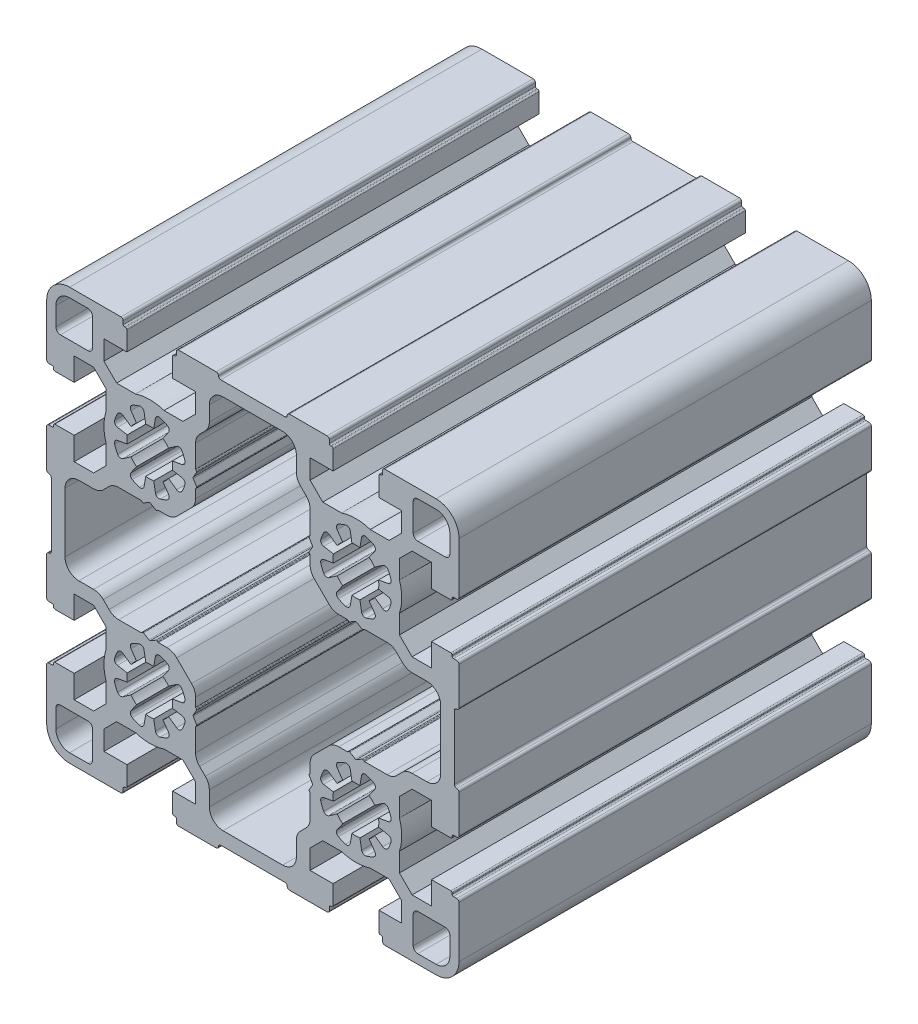
from build123d import *

# Parameters (mm, degrees)
BASE_EXTRUDE_DEPTH = 90


with BuildPart() as part:
    # Sketch1 → Base-Extrude (new body)
    with BuildSketch(Plane.XY):
        with BuildLine():
            Line((12.500065, -34.76272304), (15.262800475, -31.999987565))
            Line((15.262800475, -31.999987565), (19.377553245, -31.999987565))
            ThreePointArc((19.377553245, -31.999987565), (22.500045, -32.499985925), (25.622536755, -31.999987565))
            Line((25.622536755, -31.999987565), (29.737289525, -31.999987565))
            Line((29.737289525, -31.999987565), (32.500025, -34.76272304))
            Line((32.500025, -34.76272304), (32.500025, -39.000012))
            Line((32.500025, -39.000012), (27.500215, -39.000012))
            Line((27.500215, -39.000012), (27.500215, -43.2000036))
            ThreePointArc((27.500215, -43.2000036), (27.588084224, -43.412135897), (27.8002174, -43.500003))
            Line((27.8002174, -43.500003), (28.000214, -43.500003))
            ThreePointArc((28.000214, -43.500003), (28.212343176, -43.58787176), (28.3002084, -43.8000024))
            Line((28.3002084, -43.8000024), (28.3002084, -44.500001))
            ThreePointArc((28.3002084, -44.500001), (28.446654607, -44.853553793), (28.8002074, -45))
            Line((28.8002074, -45), (40.000013735, -45))
            ThreePointArc((40.000013735, -45), (43.535537929, -43.535537929), (45, -40.000013735))
            Line((45, -40.000013735), (45, -28.7999414))
            ThreePointArc((45, -28.7999414), (44.853553793, -28.446388607), (44.500001, -28.2999424))
            Line((44.500001, -28.2999424), (43.8000054, -28.2999424))
            ThreePointArc((43.8000054, -28.2999424), (43.587872431, -28.212075797), (43.500003, -27.999944))
            Line((43.500003, -27.999944), (43.500003, -27.7999434))
            ThreePointArc((43.500003, -27.7999434), (43.412133569, -27.587811603), (43.2000006, -27.499945))
            Line((43.2000006, -27.499945), (39.000192, -27.499945))
            Line((39.000192, -27.499945), (39.000192, -32.499935))
            Line((39.000192, -32.499935), (34.762941475, -32.499935))
            Line((34.762941475, -32.499935), (32.000206, -29.737198525))
            Line((32.000206, -29.737198525), (32.000206, -25.622447755))
            ThreePointArc((32.000206, -25.622447755), (32.50020452, -22.499955), (32.000206, -19.377462245))
            Line((32.000206, -19.377462245), (32.000206, -15.262710475))
            Line((32.000206, -15.262710475), (34.762941475, -12.499975))
            Line((34.762941475, -12.499975), (39.000012, -12.499975))
            Line((39.000012, -12.499975), (39.000012, -17.499965))
            Line((39.000012, -17.499965), (43.2000006, -17.499965))
            ThreePointArc((43.2000006, -17.499965), (43.412133569, -17.412098397), (43.500003, -17.1999666))
            Line((43.500003, -17.1999666), (43.500003, -16.999966))
            ThreePointArc((43.500003, -16.999966), (43.587872431, -16.787834203), (43.8000054, -16.6999676))
            Line((43.8000054, -16.6999676), (44.500001, -16.6999676))
            ThreePointArc((44.500001, -16.6999676), (44.853553793, -16.553521393), (45, -16.1999686))
            Line((45, -16.1999686), (45, -7.999984))
            ThreePointArc((45, -7.999984), (44.853553793, -7.646431207), (44.500001, -7.499985))
            ThreePointArc((44.500001, -7.499985), (44.146448207, -7.353538793), (44.000002, -6.999986))
            Line((44.000002, -6.999986), (44.000002, 6.999986))
            ThreePointArc((44.000002, 6.999986), (44.146448207, 7.353538793), (44.500001, 7.499985))
            ThreePointArc((44.500001, 7.499985), (44.853553793, 7.646431207), (45, 7.999984))
            Line((45, 7.999984), (45, 16.1999686))
            ThreePointArc((45, 16.1999686), (44.853553793, 16.553521393), (44.500001, 16.6999676))
            Line((44.500001, 16.6999676), (43.8000054, 16.6999676))
            ThreePointArc((43.8000054, 16.6999676), (43.587872431, 16.787834203), (43.500003, 16.999966))
            Line((43.500003, 16.999966), (43.500003, 17.1999666))
            ThreePointArc((43.500003, 17.1999666), (43.412133569, 17.412098397), (43.2000006, 17.499965))
            Line((43.2000006, 17.499965), (39.000192, 17.499965))
            Line((39.000192, 17.499965), (39.000192, 12.50002))
            Line((39.000192, 12.50002), (34.762941474, 12.50002))
            Line((34.762941474, 12.50002), (32.000206, 15.262755474))
            Line((32.000206, 15.262755474), (32.000206, 19.377508245))
            ThreePointArc((32.000206, 19.377508245), (32.50020436, 22.5), (32.000206, 25.622491755))
            Line((32.000206, 25.622491755), (32.000206, 29.737244525))
            Line((32.000206, 29.737244525), (34.762941474, 32.49998))
            Line((34.762941474, 32.49998), (39.000012, 32.49998))
            Line((39.000012, 32.49998), (39.000012, 27.500125))
            Line((39.000012, 27.500125), (43.2000006, 27.500125))
            ThreePointArc((43.2000006, 27.500125), (43.412134397, 27.587993603), (43.500003, 27.8001274))
            Line((43.500003, 27.8001274), (43.500003, 28.000124))
            ThreePointArc((43.500003, 28.000124), (43.58787326, 28.212253797), (43.8000054, 28.3001184))
            Line((43.8000054, 28.3001184), (44.500001, 28.3001184))
            ThreePointArc((44.500001, 28.3001184), (44.853553793, 28.446564607), (45, 28.8001174))
            Line((45, 28.8001174), (45, 40.000013735))
            ThreePointArc((45, 40.000013735), (43.535537929, 43.535537929), (40.000013735, 45))
            Line((40.000013735, 45), (28.8000354, 45))
            ThreePointArc((28.8000354, 45), (28.446482607, 44.853553793), (28.3000364, 44.500001))
            Line((28.3000364, 44.500001), (28.3000364, 43.8000054))
            ThreePointArc((28.3000364, 43.8000054), (28.212167797, 43.587871603), (28.000034, 43.500003))
            Line((28.000034, 43.500003), (27.8000374, 43.500003))
            ThreePointArc((27.8000374, 43.500003), (27.587903603, 43.412134397), (27.500035, 43.2000006))
            Line((27.500035, 43.2000006), (27.500035, 39.000012))
            Line((27.500035, 39.000012), (32.499865, 39.000012))
            Line((32.499865, 39.000012), (32.499865, 34.762761475))
            Line((32.499865, 34.762761475), (29.737129525, 32.000026))
            Line((29.737129525, 32.000026), (25.622376755, 32.000026))
            ThreePointArc((25.622376755, 32.000026), (22.499885, 32.50002436), (19.377393245, 32.000026))
            Line((19.377393245, 32.000026), (15.262640475, 32.000026))
            Line((15.262640475, 32.000026), (12.499905, 34.762761475))
            Line((12.499905, 34.762761475), (12.499905, 39.000012))
            Line((12.499905, 39.000012), (17.499895, 39.000012))
            Line((17.499895, 39.000012), (17.499895, 43.2000006))
            ThreePointArc((17.499895, 43.2000006), (17.412028397, 43.412133569), (17.1998966, 43.500003))
            Line((17.1998966, 43.500003), (16.999896, 43.500003))
            ThreePointArc((16.999896, 43.500003), (16.787764203, 43.587872431), (16.6998976, 43.8000054))
            Line((16.6998976, 43.8000054), (16.6998976, 44.500001))
            ThreePointArc((16.6998976, 44.500001), (16.553451393, 44.853553793), (16.1998986, 45))
            Line((16.1998986, 45), (7.999914, 45))
            ThreePointArc((7.999914, 45), (7.646361207, 44.853553793), (7.499915, 44.500001))
            ThreePointArc((7.499915, 44.500001), (7.353468793, 44.146448207), (6.999916, 44.000002))
            Line((6.999916, 44.000002), (-7.000056, 44.000002))
            ThreePointArc((-7.000056, 44.000002), (-7.353608793, 44.146448207), (-7.500055, 44.500001))
            ThreePointArc((-7.500055, 44.500001), (-7.646501207, 44.853553793), (-8.000054, 45))
            Line((-8.000054, 45), (-16.2000386, 45))
            ThreePointArc((-16.2000386, 45), (-16.553591393, 44.853553793), (-16.7000376, 44.500001))
            Line((-16.7000376, 44.500001), (-16.7000376, 43.8000054))
            ThreePointArc((-16.7000376, 43.8000054), (-16.787904203, 43.587872431), (-17.000036, 43.500003))
            Line((-17.000036, 43.500003), (-17.2000366, 43.500003))
            ThreePointArc((-17.2000366, 43.500003), (-17.412168397, 43.412133569), (-17.500035, 43.2000006))
            Line((-17.500035, 43.2000006), (-17.500035, 39.000012))
            Line((-17.500035, 39.000012), (-12.500065, 39.000012))
            Line((-12.500065, 39.000012), (-12.500065, 34.762761475))
            Line((-12.500065, 34.762761475), (-15.262800475, 32.000026))
            Line((-15.262800475, 32.000026), (-19.377552245, 32.000026))
            ThreePointArc((-19.377552245, 32.000026), (-22.500045, 32.50002452), (-25.622537755, 32.000026))
            Line((-25.622537755, 32.000026), (-29.737288525, 32.000026))
            Line((-29.737288525, 32.000026), (-32.500025, 34.762761475))
            Line((-32.500025, 34.762761475), (-32.500025, 39.000012))
            Line((-32.500025, 39.000012), (-27.500035, 39.000012))
            Line((-27.500035, 39.000012), (-27.500035, 43.2000006))
            ThreePointArc((-27.500035, 43.2000006), (-27.587901603, 43.412133569), (-27.8000334, 43.500003))
            Line((-27.8000334, 43.500003), (-28.000034, 43.500003))
            ThreePointArc((-28.000034, 43.500003), (-28.212165797, 43.587872431), (-28.3000324, 43.8000054))
            Line((-28.3000324, 43.8000054), (-28.3000324, 44.500001))
            ThreePointArc((-28.3000324, 44.500001), (-28.446478607, 44.853553793), (-28.8000314, 45))
            Line((-28.8000314, 45), (-40.000013735, 45))
            ThreePointArc((-40.000013735, 45), (-43.535537929, 43.535537929), (-45, 40.000013735))
            Line((-45, 40.000013735), (-45, 28.7999454))
            ThreePointArc((-45, 28.7999454), (-44.853553793, 28.446392607), (-44.500001, 28.2999464))
            Line((-44.500001, 28.2999464), (-43.8000024, 28.2999464))
            ThreePointArc((-43.8000024, 28.2999464), (-43.587870103, 28.212077176), (-43.500003, 27.999944))
            Line((-43.500003, 27.999944), (-43.500003, 27.7999474))
            ThreePointArc((-43.500003, 27.7999474), (-43.412135897, 27.587814224), (-43.2000036, 27.499945))
            Line((-43.2000036, 27.499945), (-39.000012, 27.499945))
            Line((-39.000012, 27.499945), (-39.000012, 32.499935))
            Line((-39.000012, 32.499935), (-34.762761475, 32.499935))
            Line((-34.762761475, 32.499935), (-32.000026, 29.737199525))
            Line((-32.000026, 29.737199525), (-32.000026, 25.622446755))
            ThreePointArc((-32.000026, 25.622446755), (-32.50002436, 22.499955), (-32.000026, 19.377463245))
            Line((-32.000026, 19.377463245), (-32.000026, 15.262710475))
            Line((-32.000026, 15.262710475), (-34.762761475, 12.499975))
            Line((-34.762761475, 12.499975), (-39.000012, 12.499975))
            Line((-39.000012, 12.499975), (-39.000012, 17.499965))
            Line((-39.000012, 17.499965), (-43.2000036, 17.499965))
            ThreePointArc((-43.2000036, 17.499965), (-43.412135069, 17.412097776), (-43.500003, 17.1999666))
            Line((-43.500003, 17.1999666), (-43.500003, 16.999966))
            ThreePointArc((-43.500003, 16.999966), (-43.587870931, 16.787834824), (-43.8000024, 16.6999676))
            Line((-43.8000024, 16.6999676), (-44.500001, 16.6999676))
            ThreePointArc((-44.500001, 16.6999676), (-44.853553793, 16.553521393), (-45, 16.1999686))
            Line((-45, 16.1999686), (-45, 7.999984))
            ThreePointArc((-45, 7.999984), (-44.853553793, 7.646431207), (-44.500001, 7.499985))
            ThreePointArc((-44.500001, 7.499985), (-44.146448207, 7.353538793), (-44.000002, 6.999986))
            Line((-44.000002, 6.999986), (-44.000002, -6.999986))
            ThreePointArc((-44.000002, -6.999986), (-44.146448207, -7.353538793), (-44.500001, -7.499985))
            ThreePointArc((-44.500001, -7.499985), (-44.853553793, -7.646431207), (-45, -7.999984))
            Line((-45, -7.999984), (-45, -16.1999686))
            ThreePointArc((-45, -16.1999686), (-44.853553793, -16.553521393), (-44.500001, -16.6999676))
            Line((-44.500001, -16.6999676), (-43.8000024, -16.6999676))
            ThreePointArc((-43.8000024, -16.6999676), (-43.587870931, -16.787834824), (-43.500003, -16.999966))
            Line((-43.500003, -16.999966), (-43.500003, -17.1999666))
            ThreePointArc((-43.500003, -17.1999666), (-43.412135069, -17.412097776), (-43.2000036, -17.499965))
            Line((-43.2000036, -17.499965), (-39.000012, -17.499965))
            Line((-39.000012, -17.499965), (-39.000012, -12.499975))
            Line((-39.000012, -12.499975), (-34.762761475, -12.499975))
            Line((-34.762761475, -12.499975), (-32.000026, -15.262710475))
            Line((-32.000026, -15.262710475), (-32.000026, -19.377462245))
            ThreePointArc((-32.000026, -19.377462245), (-32.50002452, -22.499955), (-32.000026, -25.622447755))
            Line((-32.000026, -25.622447755), (-32.000026, -29.737198525))
            Line((-32.000026, -29.737198525), (-34.762761475, -32.499935))
            Line((-34.762761475, -32.499935), (-39.000012, -32.499935))
            Line((-39.000012, -32.499935), (-39.000012, -27.499945))
            Line((-39.000012, -27.499945), (-43.2000036, -27.499945))
            ThreePointArc((-43.2000036, -27.499945), (-43.412135069, -27.587812224), (-43.500003, -27.7999434))
            Line((-43.500003, -27.7999434), (-43.500003, -27.999944))
            ThreePointArc((-43.500003, -27.999944), (-43.587870931, -28.212075176), (-43.8000024, -28.2999424))
            Line((-43.8000024, -28.2999424), (-44.500001, -28.2999424))
            ThreePointArc((-44.500001, -28.2999424), (-44.853553793, -28.446388607), (-45, -28.7999414))
            Line((-45, -28.7999414), (-45, -40.000013735))
            ThreePointArc((-45, -40.000013735), (-43.535537929, -43.535537929), (-40.000013735, -45))
            Line((-40.000013735, -45), (-28.8000314, -45))
            ThreePointArc((-28.8000314, -45), (-28.446478607, -44.853553793), (-28.3000324, -44.500001))
            Line((-28.3000324, -44.500001), (-28.3000324, -43.8000024))
            ThreePointArc((-28.3000324, -43.8000024), (-28.212165176, -43.587870931), (-28.000034, -43.500003))
            Line((-28.000034, -43.500003), (-27.8000334, -43.500003))
            ThreePointArc((-27.8000334, -43.500003), (-27.587902224, -43.412135069), (-27.500035, -43.2000036))
            Line((-27.500035, -43.2000036), (-27.500035, -39.000012))
            Line((-27.500035, -39.000012), (-32.500025, -39.000012))
            Line((-32.500025, -39.000012), (-32.500025, -34.762761475))
            Line((-32.500025, -34.762761475), (-29.737288525, -32.000026))
            Line((-29.737288525, -32.000026), (-25.622537755, -32.000026))
            ThreePointArc((-25.622537755, -32.000026), (-22.500045, -32.50002452), (-19.377552245, -32.000026))
            Line((-19.377552245, -32.000026), (-15.262800475, -32.000026))
            Line((-15.262800475, -32.000026), (-12.500065, -34.762761475))
            Line((-12.500065, -34.762761475), (-12.500065, -39.000012))
            Line((-12.500065, -39.000012), (-17.500055, -39.000012))
            Line((-17.500055, -39.000012), (-17.500055, -43.2000036))
            ThreePointArc((-17.500055, -43.2000036), (-17.412187776, -43.412135069), (-17.2000566, -43.500003))
            Line((-17.2000566, -43.500003), (-17.000056, -43.500003))
            ThreePointArc((-17.000056, -43.500003), (-16.787924824, -43.587870931), (-16.7000576, -43.8000024))
            Line((-16.7000576, -43.8000024), (-16.7000576, -44.500001))
            ThreePointArc((-16.7000576, -44.500001), (-16.553611393, -44.853553793), (-16.2000586, -45))
            Line((-16.2000586, -45), (-8.000074, -45))
            ThreePointArc((-8.000074, -45), (-7.646521207, -44.853553793), (-7.500075, -44.500001))
            ThreePointArc((-7.500075, -44.500001), (-7.353628793, -44.146448207), (-7.000076, -44.000002))
            Line((-7.000076, -44.000002), (6.999896, -44.000002))
            ThreePointArc((6.999896, -44.000002), (7.353448793, -44.146448207), (7.499895, -44.500001))
            ThreePointArc((7.499895, -44.500001), (7.646341207, -44.853553793), (7.999894, -45))
            Line((7.999894, -45), (16.1998786, -45))
            ThreePointArc((16.1998786, -45), (16.553431393, -44.853553793), (16.6998776, -44.500001))
            Line((16.6998776, -44.500001), (16.6998776, -43.8000024))
            ThreePointArc((16.6998776, -43.8000024), (16.787744824, -43.587870931), (16.999876, -43.500003))
            Line((16.999876, -43.500003), (17.1998766, -43.500003))
            ThreePointArc((17.1998766, -43.500003), (17.412007776, -43.412135069), (17.499875, -43.2000036))
            Line((17.499875, -43.2000036), (17.499875, -38.999973565))
            Line((17.499875, -38.999973565), (12.500065, -38.999973565))
            Line((12.500065, -38.999973565), (12.500065, -34.76272304))
        make_face()
        with BuildLine():
            Line((12.294798432, -21.132865734), (12.989033032, -22.335315335))
            ThreePointArc((12.989033032, -22.335315335), (13.029225168, -22.485314535), (12.989033032, -22.635313735))
            Line((12.989033032, -22.635313735), (12.277891455, -23.867044272))
            ThreePointArc((12.277891455, -23.867044272), (12.252807503, -23.993150123), (12.309675391, -24.108466789))
            Line((12.309675391, -24.108466789), (12.441397128, -24.240185526))
            ThreePointArc((12.441397128, -24.240185526), (12.484751208, -24.305069962), (12.499975011, -24.381606243))
            Line((12.499975011, -24.381606243), (12.499975011, -29.277400451))
            ThreePointArc((12.499975011, -29.277400451), (12.271612969, -30.425448253), (11.621295768, -31.398716209))
            Line((11.621295768, -31.398716209), (10.378660253, -32.641354723))
            ThreePointArc((10.378660253, -32.641354723), (9.728343052, -33.614622679), (9.499981011, -34.762670481))
            Line((9.499981011, -34.762670481), (9.499981011, -37.999924006))
            ThreePointArc((9.499981011, -37.999924006), (8.621303768, -40.121240763), (6.499987011, -40.999918006))
            Line((6.499987011, -40.999918006), (-6.499986989, -40.999918006))
            ThreePointArc((-6.499986989, -40.999918006), (-8.621303747, -40.121240763), (-9.499980989, -37.999924006))
            Line((-9.499980989, -37.999924006), (-9.499980989, -34.762670481))
            ThreePointArc((-9.499980989, -34.762670481), (-9.728343031, -33.614622679), (-10.378660232, -32.641354723))
            Line((-10.378660232, -32.641354723), (-11.621295747, -31.398716209))
            ThreePointArc((-11.621295747, -31.398716209), (-12.271612948, -30.425448253), (-12.499974989, -29.277400451))
            Line((-12.499974989, -29.277400451), (-12.499974989, -24.381606243))
            ThreePointArc((-12.499974989, -24.381606243), (-12.484751187, -24.305069962), (-12.441397107, -24.240185526))
            Line((-12.441397107, -24.240185526), (-12.30967537, -24.108466789))
            ThreePointArc((-12.30967537, -24.108466789), (-12.252807482, -23.993150123), (-12.277891434, -23.867044272))
            Line((-12.277891434, -23.867044272), (-12.989033011, -22.635313735))
            ThreePointArc((-12.989033011, -22.635313735), (-13.029225147, -22.485314535), (-12.989033011, -22.335315335))
            Line((-12.989033011, -22.335315335), (-12.29479841, -21.132865734))
            ThreePointArc((-12.29479841, -21.132865734), (-12.269714459, -21.006759883), (-12.326582347, -20.891443217))
            Line((-12.326582347, -20.891443217), (-12.441397117, -20.776630447))
            ThreePointArc((-12.441397117, -20.776630447), (-12.484751098, -20.71174651), (-12.499975, -20.635210729))
            Line((-12.499975, -20.635210729), (-12.499975, -18.742602515))
            ThreePointArc((-12.499975, -18.742602515), (-12.728335682, -17.594552774), (-13.378654243, -16.621283757))
            Line((-13.378654243, -16.621283757), (-16.621289757, -13.378652243))
            ThreePointArc((-16.621289757, -13.378652243), (-17.594557912, -12.728336041), (-18.742605515, -12.499975))
            Line((-18.742605515, -12.499975), (-20.63520673, -12.499975))
            ThreePointArc((-20.63520673, -12.499975), (-20.71174301, -12.484751197), (-20.776627447, -12.441397117))
            Line((-20.776627447, -12.441397117), (-20.891441217, -12.326582347))
            ThreePointArc((-20.891441217, -12.326582347), (-21.006756883, -12.269714798), (-21.132861734, -12.29479841))
            Line((-21.132861734, -12.29479841), (-22.335315329, -12.989033022))
            ThreePointArc((-22.335315329, -12.989033022), (-22.485314529, -13.029225158), (-22.635313729, -12.989033022))
            Line((-22.635313729, -12.989033022), (-23.867048266, -12.277891444))
            ThreePointArc((-23.867048266, -12.277891444), (-23.993154148, -12.252807251), (-24.108470783, -12.309675381))
            Line((-24.108470783, -12.309675381), (-24.24018552, -12.441397117))
            ThreePointArc((-24.24018552, -12.441397117), (-24.305070898, -12.484751538), (-24.381608237, -12.499975))
            Line((-24.381608237, -12.499975), (-29.277400445, -12.499975))
            ThreePointArc((-29.277400445, -12.499975), (-30.425446849, -12.27161476), (-31.398714202, -11.621299757))
            Line((-31.398714202, -11.621299757), (-32.641359717, -10.378656243))
            ThreePointArc((-32.641359717, -10.378656243), (-33.614627071, -9.72834124), (-34.762673475, -9.499981))
            Line((-34.762673475, -9.499981), (-37.999924, -9.499981))
            ThreePointArc((-37.999924, -9.499981), (-40.121240757, -8.621303757), (-40.999918, -6.499987))
            Line((-40.999918, -6.499987), (-40.999918, 6.499987))
            ThreePointArc((-40.999918, 6.499987), (-40.121240757, 8.621303757), (-37.999924, 9.499981))
            Line((-37.999924, 9.499981), (-34.762673475, 9.499981))
            ThreePointArc((-34.762673475, 9.499981), (-33.614627071, 9.72834124), (-32.641359717, 10.378656243))
            Line((-32.641359717, 10.378656243), (-31.398714202, 11.621299757))
            ThreePointArc((-31.398714202, 11.621299757), (-30.425446849, 12.27161476), (-29.277400445, 12.499975))
            Line((-29.277400445, 12.499975), (-24.381608237, 12.499975))
            ThreePointArc((-24.381608237, 12.499975), (-24.305070898, 12.484751538), (-24.24018552, 12.441397117))
            Line((-24.24018552, 12.441397117), (-24.108470783, 12.309675381))
            ThreePointArc((-24.108470783, 12.309675381), (-23.993154148, 12.252807251), (-23.867048266, 12.277891444))
            Line((-23.867048266, 12.277891444), (-22.635313729, 12.989033022))
            ThreePointArc((-22.635313729, 12.989033022), (-22.485314529, 13.029225158), (-22.335315329, 12.989033022))
            Line((-22.335315329, 12.989033022), (-21.132861734, 12.29479841))
            ThreePointArc((-21.132861734, 12.29479841), (-21.006756883, 12.269714798), (-20.891441217, 12.326582347))
            Line((-20.891441217, 12.326582347), (-20.776627447, 12.441397117))
            ThreePointArc((-20.776627447, 12.441397117), (-20.71174301, 12.484751197), (-20.63520673, 12.499975))
            Line((-20.63520673, 12.499975), (-18.742605515, 12.499975))
            ThreePointArc((-18.742605515, 12.499975), (-17.594558111, 12.728335041), (-16.621289757, 13.378650243))
            Line((-16.621289757, 13.378650243), (-13.378654243, 16.621285757))
            ThreePointArc((-13.378654243, 16.621285757), (-12.72833608, 17.594552774), (-12.499975, 18.742600515))
            Line((-12.499975, 18.742600515), (-12.499975, 20.635212729))
            ThreePointArc((-12.499975, 20.635212729), (-12.484750899, 20.71174751), (-12.441397117, 20.776630447))
            Line((-12.441397117, 20.776630447), (-12.326582347, 20.891445217))
            ThreePointArc((-12.326582347, 20.891445217), (-12.269715477, 21.006758883), (-12.29479841, 21.132861734))
            Line((-12.29479841, 21.132861734), (-12.989033022, 22.335313329))
            ThreePointArc((-12.989033022, 22.335313329), (-13.029225693, 22.485314529), (-12.989033022, 22.635315729))
            Line((-12.989033022, 22.635315729), (-12.277891444, 23.867048266))
            ThreePointArc((-12.277891444, 23.867048266), (-12.252808511, 23.993151117), (-12.309675381, 24.108464783))
            Line((-12.309675381, 24.108464783), (-12.441397117, 24.24018552))
            ThreePointArc((-12.441397117, 24.24018552), (-12.484750999, 24.305068956), (-12.499975, 24.381604237))
            Line((-12.499975, 24.381604237), (-12.499975, 29.277399445))
            ThreePointArc((-12.499975, 29.277399445), (-12.271613257, 30.425448747), (-11.621295757, 31.398718202))
            Line((-11.621295757, 31.398718202), (-10.378660243, 32.641352717))
            ThreePointArc((-10.378660243, 32.641352717), (-9.728342743, 33.614622173), (-9.499981, 34.762671475))
            Line((-9.499981, 34.762671475), (-9.499981, 37.999924))
            ThreePointArc((-9.499981, 37.999924), (-8.62130376, 40.121240761), (-6.499987, 40.999918006))
            Line((-6.499987, 40.999918006), (6.499987, 40.999918006))
            ThreePointArc((6.499987, 40.999918006), (8.621303757, 40.121240763), (9.499981, 37.999924006))
            Line((9.499981, 37.999924006), (9.499981, 34.762671481))
            ThreePointArc((9.499981, 34.762671481), (9.728342743, 33.614622179), (10.378660243, 32.641352723))
            Line((10.378660243, 32.641352723), (11.621295757, 31.398718209))
            ThreePointArc((11.621295757, 31.398718209), (12.271613257, 30.425448753), (12.499975, 29.277399451))
            Line((12.499975, 29.277399451), (12.499975, 24.381604243))
            ThreePointArc((12.499975, 24.381604243), (12.484750999, 24.305068962), (12.441397117, 24.240185526))
            Line((12.441397117, 24.240185526), (12.309675381, 24.108464789))
            ThreePointArc((12.309675381, 24.108464789), (12.252808511, 23.993151123), (12.277891444, 23.867048272))
            Line((12.277891444, 23.867048272), (12.989033022, 22.635315735))
            ThreePointArc((12.989033022, 22.635315735), (13.029225693, 22.485314535), (12.989033022, 22.335313335))
            Line((12.989033022, 22.335313335), (12.29479841, 21.13286174))
            ThreePointArc((12.29479841, 21.13286174), (12.269715477, 21.00675889), (12.326582347, 20.891445223))
            Line((12.326582347, 20.891445223), (12.441397117, 20.776630453))
            ThreePointArc((12.441397117, 20.776630453), (12.484750899, 20.711747516), (12.499975, 20.635212736))
            Line((12.499975, 20.635212736), (12.499975, 18.742600521))
            ThreePointArc((12.499975, 18.742600521), (12.72833608, 17.59455278), (13.378654243, 16.621285763))
            Line((13.378654243, 16.621285763), (16.621289757, 13.378650249))
            ThreePointArc((16.621289757, 13.378650249), (17.594557111, 12.728335246), (18.742603515, 12.499975006))
            Line((18.742603515, 12.499975006), (20.63520473, 12.499975006))
            ThreePointArc((20.63520473, 12.499975006), (20.71174351, 12.484751701), (20.776630447, 12.441397123))
            Line((20.776630447, 12.441397123), (20.891437217, 12.326582353))
            ThreePointArc((20.891437217, 12.326582353), (21.006754883, 12.269714126), (21.132861734, 12.294798416))
            Line((21.132861734, 12.294798416), (22.335313329, 12.989033028))
            ThreePointArc((22.335313329, 12.989033028), (22.485314529, 13.0292257), (22.635315729, 12.989033028))
            Line((22.635315729, 12.989033028), (23.867048266, 12.27789145))
            ThreePointArc((23.867048266, 12.27789145), (23.993155148, 12.252806918), (24.108472783, 12.309675387))
            Line((24.108472783, 12.309675387), (24.24018552, 12.441397123))
            ThreePointArc((24.24018552, 12.441397123), (24.305072398, 12.484751842), (24.381611237, 12.499975006))
            Line((24.381611237, 12.499975006), (29.277399445, 12.499975006))
            ThreePointArc((29.277399445, 12.499975006), (30.425444349, 12.271614467), (31.398710202, 11.621299763))
            Line((31.398710202, 11.621299763), (32.641360717, 10.378656249))
            ThreePointArc((32.641360717, 10.378656249), (33.614626571, 9.728341545), (34.762671475, 9.499981006))
            Line((34.762671475, 9.499981006), (37.999924, 9.499981006))
            ThreePointArc((37.999924, 9.499981006), (40.12124076, 8.621303761), (40.999918, 6.499987))
            Line((40.999918, 6.499987), (40.999918, -6.499987))
            ThreePointArc((40.999918, -6.499987), (40.121240765, -8.62130375), (37.999924021, -9.499981))
            Line((37.999924021, -9.499981), (34.762671496, -9.499981))
            ThreePointArc((34.762671496, -9.499981), (33.614626592, -9.728341539), (32.641360738, -10.378656243))
            Line((32.641360738, -10.378656243), (31.398710224, -11.621299757))
            ThreePointArc((31.398710224, -11.621299757), (30.42544437, -12.271614461), (29.277399466, -12.499975))
            Line((29.277399466, -12.499975), (24.381611258, -12.499975))
            ThreePointArc((24.381611258, -12.499975), (24.305072419, -12.484751836), (24.240185541, -12.441397117))
            Line((24.240185541, -12.441397117), (24.108472804, -12.309675381))
            ThreePointArc((24.108472804, -12.309675381), (23.99315517, -12.252806912), (23.867048287, -12.277891444))
            Line((23.867048287, -12.277891444), (22.63531575, -12.989033022))
            ThreePointArc((22.63531575, -12.989033022), (22.48531455, -13.029225693), (22.33531335, -12.989033022))
            Line((22.33531335, -12.989033022), (21.132861755, -12.29479841))
            ThreePointArc((21.132861755, -12.29479841), (21.006754905, -12.26971412), (20.891437238, -12.326582347))
            Line((20.891437238, -12.326582347), (20.776630468, -12.441397117))
            ThreePointArc((20.776630468, -12.441397117), (20.711743531, -12.484751695), (20.635204751, -12.499975))
            Line((20.635204751, -12.499975), (18.742603536, -12.499975))
            ThreePointArc((18.742603536, -12.499975), (17.594556933, -12.72833624), (16.621289779, -13.378652243))
            Line((16.621289779, -13.378652243), (13.378654264, -16.621283757))
            ThreePointArc((13.378654264, -16.621283757), (12.728335704, -17.594552774), (12.499975021, -18.742602515))
            Line((12.499975021, -18.742602515), (12.499975021, -20.635210729))
            ThreePointArc((12.499975021, -20.635210729), (12.484751119, -20.71174651), (12.441397138, -20.776630447))
            Line((12.441397138, -20.776630447), (12.326582368, -20.891443217))
            ThreePointArc((12.326582368, -20.891443217), (12.26971448, -21.006759883), (12.294798432, -21.132865734))
        make_face(mode=Mode.SUBTRACT)
        with BuildLine():
            Line((-18.395790144, -28.361333627), (-19.632087262, -26.595719459))
            ThreePointArc((-19.632087262, -26.595719459), (-18.96444517, -26.03549874), (-18.404226694, -25.367854767))
            Line((-18.404226694, -25.367854767), (-16.638614225, -26.604147294))
            ThreePointArc((-16.638614225, -26.604147294), (-15.997213825, -26.72772129), (-15.477506547, -26.332032838))
            ThreePointArc((-15.477506547, -26.332032838), (-15.108954533, -25.561437125), (-14.824666853, -24.75593799))
            ThreePointArc((-14.824666853, -24.75593799), (-14.912360729, -24.108655294), (-15.453279596, -23.742497017))
            Line((-15.453279596, -23.742497017), (-17.575952849, -23.36821362))
            ThreePointArc((-17.575952849, -23.36821362), (-17.499994989, -22.499975596), (-17.575959537, -21.631738156))
            Line((-17.575959537, -21.631738156), (-15.453264029, -21.257450835))
            ThreePointArc((-15.453264029, -21.257450835), (-14.912345162, -20.891292558), (-14.824651287, -20.244009862))
            ThreePointArc((-14.824651287, -20.244009862), (-15.108938966, -19.438510727), (-15.477490981, -18.667915014))
            ThreePointArc((-15.477490981, -18.667915014), (-15.997198259, -18.272226562), (-16.638598659, -18.395800558))
            Line((-16.638598659, -18.395800558), (-18.404241237, -19.632114168))
            ThreePointArc((-18.404241237, -19.632114168), (-18.964452744, -18.96448339), (-19.63208404, -18.4042725))
            Line((-19.63208404, -18.4042725), (-18.395790144, -16.638658077))
            ThreePointArc((-18.395790144, -16.638658077), (-18.272216148, -15.997257677), (-18.6679046, -15.477550399))
            ThreePointArc((-18.6679046, -15.477550399), (-19.438500313, -15.108998385), (-20.243999448, -14.824710705))
            ThreePointArc((-20.243999448, -14.824710705), (-20.891282144, -14.912404581), (-21.257440421, -15.453323448))
            Line((-21.257440421, -15.453323448), (-21.631722672, -17.575990203))
            ThreePointArc((-21.631722672, -17.575990203), (-22.499951038, -17.500028905), (-23.368179704, -17.575986765))
            Line((-23.368179704, -17.575986765), (-23.742463101, -15.453313512))
            ThreePointArc((-23.742463101, -15.453313512), (-24.108621378, -14.912394645), (-24.755904074, -14.824700769))
            ThreePointArc((-24.755904074, -14.824700769), (-25.561403209, -15.108988449), (-26.331998922, -15.477540463))
            ThreePointArc((-26.331998922, -15.477540463), (-26.727687374, -15.997247741), (-26.604113378, -16.638648141))
            Line((-26.604113378, -16.638648141), (-25.36782085, -18.40426061))
            ThreePointArc((-25.36782085, -18.40426061), (-26.035464824, -18.964479086), (-26.595685543, -19.632121178))
            Line((-26.595685543, -19.632121178), (-28.361299711, -18.395824061))
            ThreePointArc((-28.361299711, -18.395824061), (-29.002700247, -18.272249484), (-29.522407389, -18.667938516))
            ThreePointArc((-29.522407389, -18.667938516), (-29.890959403, -19.438534229), (-30.175247083, -20.244033364))
            ThreePointArc((-30.175247083, -20.244033364), (-30.087553207, -20.89131606), (-29.54663434, -21.257474337))
            Line((-29.54663434, -21.257474337), (-27.423965586, -21.631756589))
            ThreePointArc((-27.423965586, -21.631756589), (-27.499926883, -22.499994852), (-27.423965586, -23.368233116))
            Line((-27.423965586, -23.368233116), (-29.54663434, -23.742515367))
            ThreePointArc((-29.54663434, -23.742515367), (-30.087553207, -24.108673644), (-30.175247083, -24.75595634))
            ThreePointArc((-30.175247083, -24.75595634), (-29.890959403, -25.561455475), (-29.522407389, -26.332051188))
            ThreePointArc((-29.522407389, -26.332051188), (-29.002700247, -26.72774022), (-28.361299711, -26.604165644))
            Line((-28.361299711, -26.604165644), (-26.595685543, -25.367868526))
            ThreePointArc((-26.595685543, -25.367868526), (-26.035464824, -26.035510618), (-25.36782085, -26.595729094))
            Line((-25.36782085, -26.595729094), (-26.604115378, -28.361339563))
            ThreePointArc((-26.604115378, -28.361339563), (-26.727689954, -29.002740099), (-26.332000922, -29.522447241))
            ThreePointArc((-26.332000922, -29.522447241), (-25.561405209, -29.890999255), (-24.755906074, -30.175286935))
            ThreePointArc((-24.755906074, -30.175286935), (-24.108623378, -30.087593059), (-23.742465101, -29.546674192))
            Line((-23.742465101, -29.546674192), (-23.368182328, -27.424002477))
            ThreePointArc((-23.368182328, -27.424002477), (-22.49995237, -27.499960799), (-21.631722672, -27.423999502))
            Line((-21.631722672, -27.423999502), (-21.257440421, -29.546668256))
            ThreePointArc((-21.257440421, -29.546668256), (-20.891282144, -30.087587123), (-20.243999448, -30.175280999))
            ThreePointArc((-20.243999448, -30.175280999), (-19.438500313, -29.890993319), (-18.6679046, -29.522441305))
            ThreePointArc((-18.6679046, -29.522441305), (-18.272215568, -29.002734163), (-18.395790144, -28.361333627))
        make_face(mode=Mode.SUBTRACT)
        with BuildLine():
            Line((26.604102289, -28.361293775), (25.367805172, -26.595679607))
            ThreePointArc((25.367805172, -26.595679607), (26.035447983, -26.035458168), (26.595666908, -25.367813247))
            Line((26.595666908, -25.367813247), (28.361280376, -26.604105774))
            ThreePointArc((28.361280376, -26.604105774), (29.002680776, -26.72767977), (29.522388054, -26.331991318))
            ThreePointArc((29.522388054, -26.331991318), (29.890939069, -25.561395552), (30.175225748, -24.75589647))
            ThreePointArc((30.175225748, -24.75589647), (30.087530873, -24.108613327), (29.546611006, -23.742455497))
            Line((29.546611006, -23.742455497), (27.423939996, -23.368171438))
            ThreePointArc((27.423939996, -23.368171438), (27.499897445, -22.499957532), (27.423940875, -21.631743549))
            Line((27.423940875, -21.631743549), (29.546620404, -21.257457987))
            ThreePointArc((29.546620404, -21.257457987), (30.087540271, -20.891300158), (30.175235147, -20.244017014))
            ThreePointArc((30.175235147, -20.244017014), (29.890948467, -19.438517933), (29.522397453, -18.667922167))
            ThreePointArc((29.522397453, -18.667922167), (29.002690175, -18.272233715), (28.361289775, -18.395807711))
            Line((28.361289775, -18.395807711), (26.595671637, -19.632103508))
            ThreePointArc((26.595671637, -19.632103508), (26.035451709, -18.964455558), (25.367807051, -18.404231709))
            Line((25.367807051, -18.404231709), (26.604102289, -16.638618225))
            ThreePointArc((26.604102289, -16.638618225), (26.727675285, -15.997217378), (26.331985833, -15.477510547))
            ThreePointArc((26.331985833, -15.477510547), (25.56139112, -15.108958586), (24.755892986, -14.824670853))
            ThreePointArc((24.755892986, -14.824670853), (24.10861029, -14.912364729), (23.742452013, -15.453283596))
            Line((23.742452013, -15.453283596), (23.368169761, -17.57595035))
            ThreePointArc((23.368169761, -17.57595035), (22.499942256, -17.499989053), (21.631714424, -17.575946614))
            Line((21.631714424, -17.575946614), (21.257430668, -15.453271324))
            ThreePointArc((21.257430668, -15.453271324), (20.891272391, -14.912352457), (20.243989695, -14.824658581))
            ThreePointArc((20.243989695, -14.824658581), (19.43848956, -15.108946208), (18.667892847, -15.477498276))
            ThreePointArc((18.667892847, -15.477498276), (18.272205395, -15.997206001), (18.395780391, -16.638605953))
            Line((18.395780391, -16.638605953), (19.632074919, -18.404218422))
            ThreePointArc((19.632074919, -18.404218422), (18.964429049, -18.964437795), (18.40420689, -19.632081326))
            Line((18.40420689, -19.632081326), (16.638592723, -18.395784208))
            ThreePointArc((16.638592723, -18.395784208), (15.997192187, -18.272209632), (15.477485045, -18.667898664))
            ThreePointArc((15.477485045, -18.667898664), (15.10893403, -19.438494431), (14.824647351, -20.243993512))
            ThreePointArc((14.824647351, -20.243993512), (14.912340226, -20.891275761), (15.453258093, -21.257434485))
            Line((15.453258093, -21.257434485), (17.575926848, -21.631716736))
            ThreePointArc((17.575926848, -21.631716736), (17.499965551, -22.499955), (17.575926848, -23.368193264))
            Line((17.575926848, -23.368193264), (15.453258093, -23.742475515))
            ThreePointArc((15.453258093, -23.742475515), (14.912340226, -24.108634239), (14.824647351, -24.755916488))
            ThreePointArc((14.824647351, -24.755916488), (15.10893403, -25.561415569), (15.477485045, -26.332011336))
            ThreePointArc((15.477485045, -26.332011336), (15.997192187, -26.727700368), (16.638592723, -26.604125792))
            Line((16.638592723, -26.604125792), (18.40420689, -25.367828674))
            ThreePointArc((18.40420689, -25.367828674), (18.96442761, -26.035470766), (19.632071583, -26.595689242))
            Line((19.632071583, -26.595689242), (18.395777056, -28.361299711))
            ThreePointArc((18.395777056, -28.361299711), (18.272201479, -29.0026998), (18.667889512, -29.522407389))
            ThreePointArc((18.667889512, -29.522407389), (19.438486225, -29.890959457), (20.243986359, -30.175247083))
            ThreePointArc((20.243986359, -30.175247083), (20.891269055, -30.087553207), (21.257427332, -29.54663434))
            Line((21.257427332, -29.54663434), (21.631710106, -27.423962624))
            ThreePointArc((21.631710106, -27.423962624), (22.499940064, -27.499920947), (23.368169761, -27.42395965))
            Line((23.368169761, -27.42395965), (23.742452013, -29.546628404))
            ThreePointArc((23.742452013, -29.546628404), (24.10861029, -30.087547271), (24.755892986, -30.175241147))
            ThreePointArc((24.755892986, -30.175241147), (25.56139112, -29.890953414), (26.331985833, -29.522401453))
            ThreePointArc((26.331985833, -29.522401453), (26.727675866, -29.002694758), (26.604102289, -28.361293775))
        make_face(mode=Mode.SUBTRACT)
        with BuildLine():
            Line((-34.99993, -41.999916), (-34.99993, -35.999928))
            ThreePointArc((-34.99993, -35.999928), (-35.292822414, -35.292822414), (-35.999928, -34.99993))
            Line((-35.999928, -34.99993), (-41.999916, -34.99993))
            ThreePointArc((-41.999916, -34.99993), (-42.707021586, -35.292822414), (-42.999914, -35.999928))
            Line((-42.999914, -35.999928), (-42.999914, -39.99992))
            ThreePointArc((-42.999914, -39.99992), (-42.121236757, -42.121236757), (-39.99992, -42.999914))
            Line((-39.99992, -42.999914), (-35.999928, -42.999914))
            ThreePointArc((-35.999928, -42.999914), (-35.292822414, -42.707021586), (-34.99993, -41.999916))
        make_face(mode=Mode.SUBTRACT)
        with BuildLine():
            Line((34.99993, -41.999916), (34.99993, -35.999928))
            ThreePointArc((34.99993, -35.999928), (35.292822414, -35.292822414), (35.999928, -34.99993))
            Line((35.999928, -34.99993), (41.999916, -34.99993))
            ThreePointArc((41.999916, -34.99993), (42.707021586, -35.292822414), (42.999914, -35.999928))
            Line((42.999914, -35.999928), (42.999914, -39.99992))
            ThreePointArc((42.999914, -39.99992), (42.121236757, -42.121236757), (39.99992, -42.999914))
            Line((39.99992, -42.999914), (35.999928, -42.999914))
            ThreePointArc((35.999928, -42.999914), (35.292822414, -42.707021586), (34.99993, -41.999916))
        make_face(mode=Mode.SUBTRACT)
        with BuildLine():
            Line((-18.395768262, 16.638588603), (-19.632063549, 18.404200157))
            ThreePointArc((-19.632063549, 18.404200157), (-18.96440877, 18.964429298), (-18.404180494, 19.632084802))
            Line((-18.404180494, 19.632084802), (-16.638568026, 18.395790275))
            ThreePointArc((-16.638568026, 18.395790275), (-15.997168073, 18.272215279), (-15.477460348, 18.667902731))
            ThreePointArc((-15.477460348, 18.667902731), (-15.10890828, 19.438499444), (-14.824620653, 20.243999579))
            ThreePointArc((-14.824620653, 20.243999579), (-14.912314529, 20.891282275), (-15.453233396, 21.257440552))
            Line((-15.453233396, 21.257440552), (-17.575905544, 21.631723754))
            ThreePointArc((-17.575905544, 21.631723754), (-17.499944967, 22.499973613), (-17.575909955, 23.368223085))
            Line((-17.575909955, 23.368223085), (-15.453229508, 23.742507751))
            ThreePointArc((-15.453229508, 23.742507751), (-14.912310641, 24.108666028), (-14.824616765, 24.755948724))
            ThreePointArc((-14.824616765, 24.755948724), (-15.108904498, 25.561446859), (-15.47745646, 26.332041572))
            ThreePointArc((-15.47745646, 26.332041572), (-15.99716329, 26.727731024), (-16.638564137, 26.604158028))
            Line((-16.638564137, 26.604158028), (-18.404191655, 25.367852963))
            ThreePointArc((-18.404191655, 25.367852963), (-18.964413651, 26.035497409), (-19.632058918, 26.595718427))
            Line((-19.632058918, 26.595718427), (-18.395768262, 28.361329224))
            ThreePointArc((-18.395768262, 28.361329224), (-18.272194266, 29.002729624), (-18.667882718, 29.522436902))
            ThreePointArc((-18.667882718, 29.522436902), (-19.438478484, 29.890987916), (-20.243977565, 30.175274596))
            ThreePointArc((-20.243977565, 30.175274596), (-20.891260709, 30.08757972), (-21.257418538, 29.546659853))
            Line((-21.257418538, 29.546659853), (-21.63170079, 27.423999098))
            ThreePointArc((-21.63170079, 27.423999098), (-22.499941081, 27.499960913), (-23.36818149, 27.424000448))
            Line((-23.36818149, 27.424000448), (-23.742464996, 29.546668316))
            ThreePointArc((-23.742464996, 29.546668316), (-24.108622826, 30.087588183), (-24.755905969, 30.175283059))
            ThreePointArc((-24.755905969, 30.175283059), (-25.56140505, 29.890996379), (-26.332000817, 29.522445364))
            ThreePointArc((-26.332000817, 29.522445364), (-26.727689269, 29.002738087), (-26.604115273, 28.361337687))
            Line((-26.604115273, 28.361337687), (-25.367822745, 26.595724218))
            ThreePointArc((-25.367822745, 26.595724218), (-26.035477302, 26.03549639), (-26.595705723, 25.367842331))
            Line((-26.595705723, 25.367842331), (-28.361317277, 26.604137618))
            ThreePointArc((-28.361317277, 26.604137618), (-29.00271826, 26.727711195), (-29.522424955, 26.332021162))
            ThreePointArc((-29.522424955, 26.332021162), (-29.890976916, 25.561426449), (-30.175264649, 24.755928315))
            ThreePointArc((-30.175264649, 24.755928315), (-30.087570774, 24.108645618), (-29.546651907, 23.742487341))
            Line((-29.546651907, 23.742487341), (-27.423983152, 23.36820509))
            ThreePointArc((-27.423983152, 23.36820509), (-27.499944967, 22.499960913), (-27.423983152, 21.631716736))
            Line((-27.423983152, 21.631716736), (-29.546651907, 21.257434485))
            ThreePointArc((-29.546651907, 21.257434485), (-30.087570774, 20.891276208), (-30.175264649, 20.243993512))
            ThreePointArc((-30.175264649, 20.243993512), (-29.890977023, 19.438493377), (-29.522424955, 18.667896664))
            ThreePointArc((-29.522424955, 18.667896664), (-29.002717366, 18.272208632), (-28.361317277, 18.395784208))
            Line((-28.361317277, 18.395784208), (-26.595705723, 19.632079496))
            ThreePointArc((-26.595705723, 19.632079496), (-26.035478022, 18.964426157), (-25.367824413, 18.404198777))
            Line((-25.367824413, 18.404198777), (-26.604118941, 16.638588308))
            ThreePointArc((-26.604118941, 16.638588308), (-26.727693517, 15.997187772), (-26.332004485, 15.47748063))
            ThreePointArc((-26.332004485, 15.47748063), (-25.561408718, 15.108929615), (-24.755909637, 14.824642936))
            ThreePointArc((-24.755909637, 14.824642936), (-24.108627388, 14.912335811), (-23.742468664, 15.453253678))
            Line((-23.742468664, 15.453253678), (-23.368186444, 17.575922252))
            ThreePointArc((-23.368186444, 17.575922252), (-22.499943596, 17.499960913), (-21.63170079, 17.575922728))
            Line((-21.63170079, 17.575922728), (-21.257418538, 15.453253973))
            ThreePointArc((-21.257418538, 15.453253973), (-20.891259814, 14.912336106), (-20.243977565, 14.824643231))
            ThreePointArc((-20.243977565, 14.824643231), (-19.438478484, 15.10892991), (-18.667882718, 15.477480925))
            ThreePointArc((-18.667882718, 15.477480925), (-18.272193685, 15.997188067), (-18.395768262, 16.638588603))
        make_face(mode=Mode.SUBTRACT)
        with BuildLine():
            Line((26.604102289, 16.638616225), (25.367805172, 18.404230393))
            ThreePointArc((25.367805172, 18.404230393), (26.035449423, 18.964453272), (26.595669243, 19.632100089))
            Line((26.595669243, 19.632100089), (28.361282712, 18.395805562))
            ThreePointArc((28.361282712, 18.395805562), (29.002682665, 18.272230565), (29.52239039, 18.667918017))
            ThreePointArc((29.52239039, 18.667918017), (29.890941458, 19.438514784), (30.175228084, 20.244014865))
            ThreePointArc((30.175228084, 20.244014865), (30.087533208, 20.891298008), (29.546613341, 21.257455838))
            Line((29.546613341, 21.257455838), (27.423940294, 21.631740257))
            ThreePointArc((27.423940294, 21.631740257), (27.499897445, 22.49995241), (27.423941194, 23.368164642))
            Line((27.423941194, 23.368164642), (29.546601905, 23.742446886))
            ThreePointArc((29.546601905, 23.742446886), (30.087521772, 24.108604715), (30.175216648, 24.755887859))
            ThreePointArc((30.175216648, 24.755887859), (29.890929915, 25.56138594), (29.522378954, 26.331980707))
            ThreePointArc((29.522378954, 26.331980707), (29.002672123, 26.727670158), (28.361271276, 26.604097162))
            Line((28.361271276, 26.604097162), (26.595668899, 25.367810402))
            ThreePointArc((26.595668899, 25.367810402), (26.035453481, 26.03545267), (25.367815065, 26.59567268))
            Line((25.367815065, 26.59567268), (26.604123642, 28.361306214))
            ThreePointArc((26.604123642, 28.361306214), (26.727696639, 29.002707061), (26.332007187, 29.522413892))
            ThreePointArc((26.332007187, 29.522413892), (25.56141242, 29.890964853), (24.755914339, 30.175251586))
            ThreePointArc((24.755914339, 30.175251586), (24.108631196, 30.087556711), (23.742473366, 29.546636844))
            Line((23.742473366, 29.546636844), (23.368187659, 27.423956494))
            ThreePointArc((23.368187659, 27.423956494), (22.499952526, 27.499920947), (21.631716755, 27.423963797))
            Line((21.631716755, 27.423963797), (21.257432336, 29.546636844))
            ThreePointArc((21.257432336, 29.546636844), (20.891274506, 30.087556711), (20.243991363, 30.175251586))
            ThreePointArc((20.243991363, 30.175251586), (19.438491282, 29.89096496), (18.667894515, 29.522413892))
            ThreePointArc((18.667894515, 29.522413892), (18.272207063, 29.002706167), (18.395782059, 28.361306214))
            Line((18.395782059, 28.361306214), (19.632076587, 26.595692746))
            ThreePointArc((19.632076587, 26.595692746), (18.964429769, 26.035472925), (18.40420689, 25.367828674))
            Line((18.40420689, 25.367828674), (16.638592723, 26.604125792))
            ThreePointArc((16.638592723, 26.604125792), (15.99719174, 26.727699368), (15.477485045, 26.332009336))
            ThreePointArc((15.477485045, 26.332009336), (15.108934084, 25.561414569), (14.824647351, 24.755916488))
            ThreePointArc((14.824647351, 24.755916488), (14.912340226, 24.108634239), (15.453258093, 23.742475515))
            Line((15.453258093, 23.742475515), (17.575926848, 23.368193264))
            ThreePointArc((17.575926848, 23.368193264), (17.499965551, 22.499955), (17.575926848, 21.631716736))
            Line((17.575926848, 21.631716736), (15.453258093, 21.257434485))
            ThreePointArc((15.453258093, 21.257434485), (14.912340226, 20.891275761), (14.824647351, 20.243993512))
            ThreePointArc((14.824647351, 20.243993512), (15.108933977, 19.438493431), (15.477485045, 18.667896664))
            ThreePointArc((15.477485045, 18.667896664), (15.997192634, 18.272208632), (16.638592723, 18.395784208))
            Line((16.638592723, 18.395784208), (18.40420689, 19.632081326))
            ThreePointArc((18.40420689, 19.632081326), (18.96442761, 18.964439234), (19.632071583, 18.404220758))
            Line((19.632071583, 18.404220758), (18.395777056, 16.638610289))
            ThreePointArc((18.395777056, 16.638610289), (18.272201479, 15.9972102), (18.667889512, 15.477502611))
            ThreePointArc((18.667889512, 15.477502611), (19.438486278, 15.108951543), (20.243986359, 14.824664917))
            ThreePointArc((20.243986359, 14.824664917), (20.891268608, 14.912357793), (21.257427332, 15.45327566))
            Line((21.257427332, 15.45327566), (21.631710106, 17.575947376))
            ThreePointArc((21.631710106, 17.575947376), (22.499940064, 17.499989053), (23.368169761, 17.57595035))
            Line((23.368169761, 17.57595035), (23.742452013, 15.453281596))
            ThreePointArc((23.742452013, 15.453281596), (24.108610737, 14.912363729), (24.755892986, 14.824670853))
            ThreePointArc((24.755892986, 14.824670853), (25.561391067, 15.108957586), (26.331985833, 15.477508547))
            ThreePointArc((26.331985833, 15.477508547), (26.727675866, 15.997215242), (26.604102289, 16.638616225))
        make_face(mode=Mode.SUBTRACT)
        with BuildLine():
            Line((-34.99993, 35.999928), (-34.99993, 41.999916))
            ThreePointArc((-34.99993, 41.999916), (-35.292822414, 42.707021586), (-35.999928, 42.999914))
            Line((-35.999928, 42.999914), (-39.99992, 42.999914))
            ThreePointArc((-39.99992, 42.999914), (-42.121236757, 42.121236757), (-42.999914, 39.99992))
            Line((-42.999914, 39.99992), (-42.999914, 35.999928))
            ThreePointArc((-42.999914, 35.999928), (-42.707021586, 35.292822414), (-41.999916, 34.99993))
            Line((-41.999916, 34.99993), (-35.999928, 34.99993))
            ThreePointArc((-35.999928, 34.99993), (-35.292822414, 35.292822414), (-34.99993, 35.999928))
        make_face(mode=Mode.SUBTRACT)
        with BuildLine():
            Line((34.99993, 35.999928), (34.99993, 41.999916))
            ThreePointArc((34.99993, 41.999916), (35.292822414, 42.707021586), (35.999928, 42.999914))
            Line((35.999928, 42.999914), (39.99992, 42.999914))
            ThreePointArc((39.99992, 42.999914), (42.121236757, 42.121236757), (42.999914, 39.99992))
            Line((42.999914, 39.99992), (42.999914, 35.999928))
            ThreePointArc((42.999914, 35.999928), (42.707021586, 35.292822414), (41.999916, 34.99993))
            Line((41.999916, 34.99993), (35.999928, 34.99993))
            ThreePointArc((35.999928, 34.99993), (35.292822414, 35.292822414), (34.99993, 35.999928))
        make_face(mode=Mode.SUBTRACT)
    extrude(amount=-BASE_EXTRUDE_DEPTH)


solid = part.part
